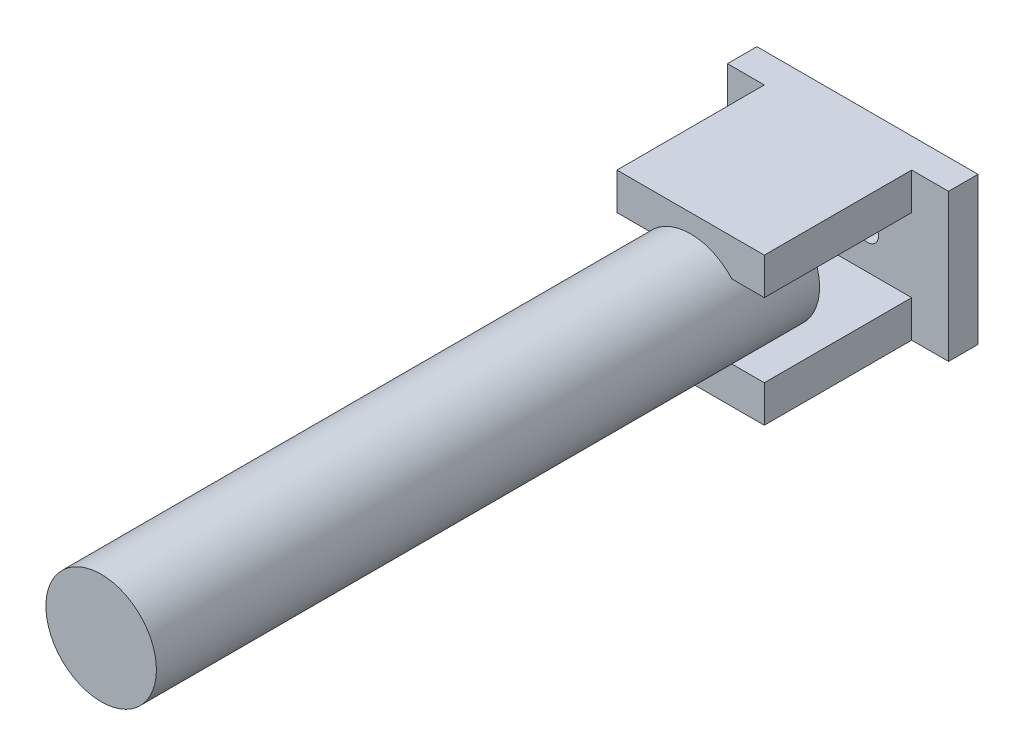
from build123d import *

# Parameters (mm, degrees)
SKETCH_1_W           = 30
SKETCH_1_H           = 20
SKETCH_1_R           = 1.5
EXTRUDE_1_DEPTH      = 4
SKETCH_2_W           = 20
SKETCH_2_H           = 5
EXTRUDE_2_DEPTH      = 20
SKETCH_3_R           = 7.5
EXTRUDE_3_DEPTH      = 80
EXTRUDE_3_DEPTH_BACK = 10


with BuildPart() as part:
    # 草图1 → 凸台-拉伸1 (new body)
    with BuildSketch(Plane.XY):
        with Locations((1.097142857, 0.694285714)):
            Rectangle(SKETCH_1_W, SKETCH_1_H)
        with Locations((-2.902857143, 0.694285714)):
            Circle(SKETCH_1_R, mode=Mode.SUBTRACT)
        with Locations((5.097142857, 0.694285714)):
            Circle(SKETCH_1_R, mode=Mode.SUBTRACT)
    extrude(amount=EXTRUDE_1_DEPTH)

    # 草图2 → 凸台-拉伸2 (add)
    with BuildSketch(Plane.XY.offset(4)):
        with Locations((1.097142857, 8.194285714)):
            Rectangle(SKETCH_2_W, SKETCH_2_H)
        with Locations((1.097142857, -6.805714286)):
            Rectangle(SKETCH_2_W, SKETCH_2_H)
    extrude(amount=EXTRUDE_2_DEPTH)

    # 草图3 → 凸台-拉伸3 (add, two sides)
    with BuildSketch(Plane.XY.offset(24)) as extrude_3_sk:
        with Locations((1.097142857, 0.694285714)):
            Circle(SKETCH_3_R)
    extrude(amount=EXTRUDE_3_DEPTH)
    extrude(extrude_3_sk.sketch, amount=-EXTRUDE_3_DEPTH_BACK)


solid = part.part
